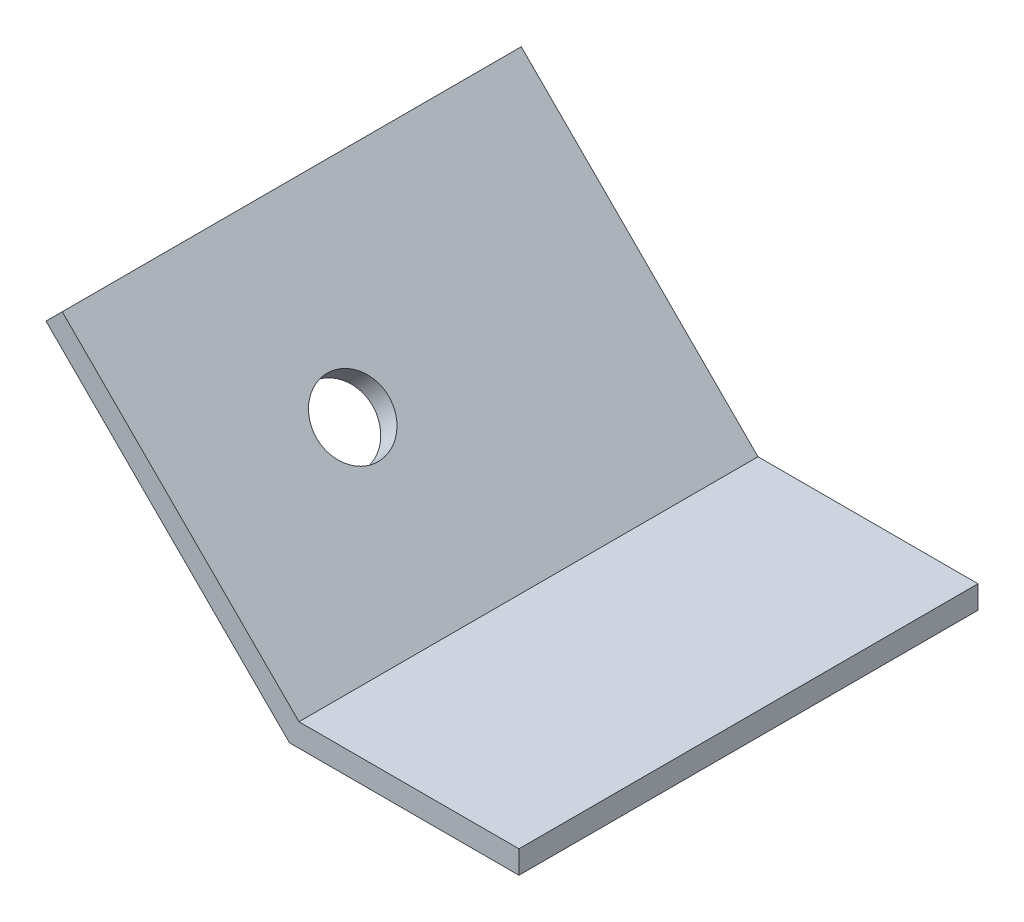
from build123d import *

# Parameters (mm, degrees)
BASE_DEPTH      = 50.8
AXLE_HOLE_REACH = 23.59
SKETCH2_R       = 4


with BuildPart() as part:
    # Sketch1 → base (new body)
    with BuildSketch(Plane.XY):
        Polygon((-26.940768363, 26.940768363), (0, 0), (25.4, 0), (25.4, 2.54), (1.052102448, 2.54), (-25.144717139, 28.736819587), align=None)
    extrude(amount=BASE_DEPTH)

    # Sketch2 → axle hole (cut, up to next)
    with BuildSketch(Plane(origin=(1.796051224, 1.796051224, 0), x_dir=(0, 0, -1), z_dir=(0.707106781, 0.707106781, 0)), mode=Mode.PRIVATE) as axle_hole_sk1:
        with Locations((-31.75, 19.576051224)):
            Circle(SKETCH2_R)
    axle_hole_tool1 = extrude(axle_hole_sk1.sketch, amount=-AXLE_HOLE_REACH, mode=Mode.PRIVATE) & part.part
    add(axle_hole_tool1.solids().sort_by_distance((-12.046307, 15.63841, 31.75))[0], mode=Mode.SUBTRACT)


solid = part.part
